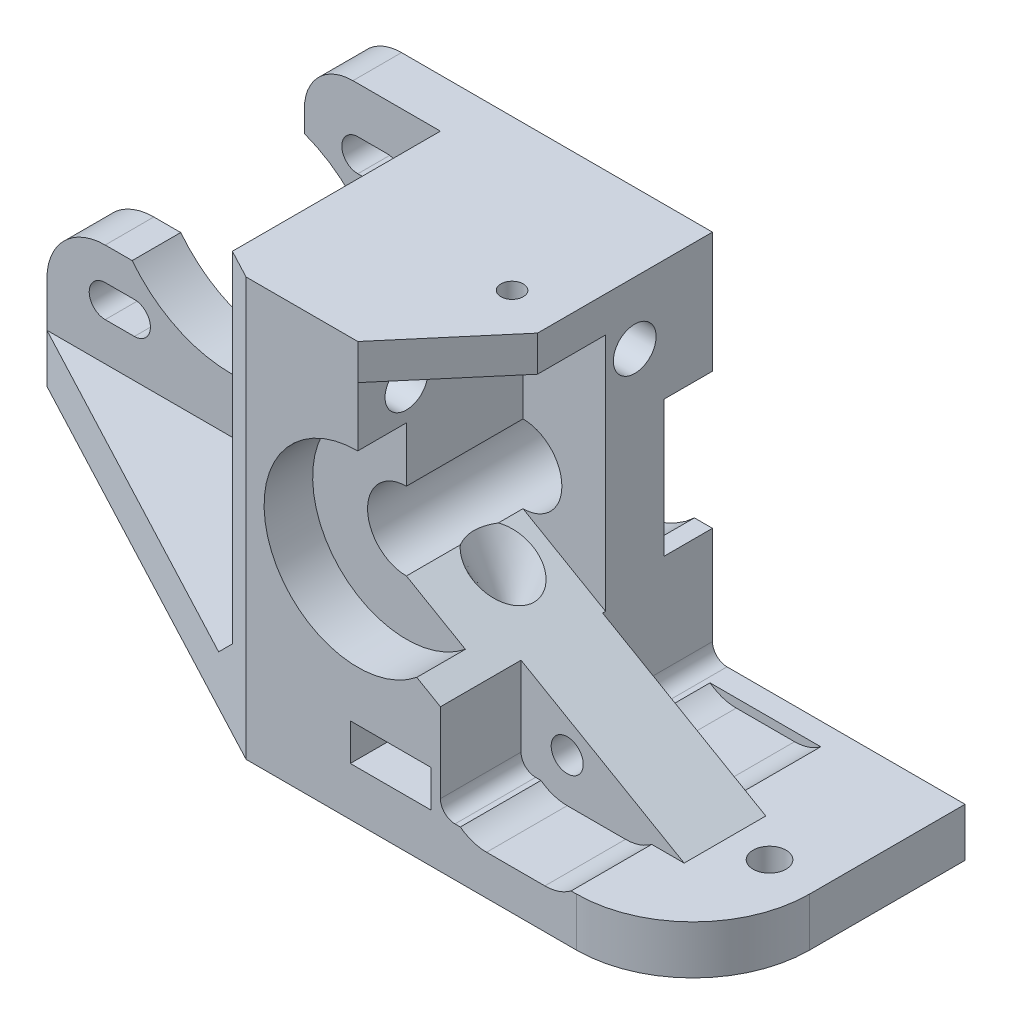
from build123d import *

# Parameters (mm, degrees)
SKETCH1_R                = 4
BOSS_EXTRUDE1_DEPTH      = 28
SKETCH2_W                = 40.5
SKETCH2_H                = 38
CUT_EXTRUDE1_DEPTH       = 23
SKETCH3_R                = 9.65
CUT_EXTRUDE2_DEPTH       = 5
SKETCH8_R                = 1.15
CUT_EXTRUDE7_DEPTH       = 44
CHAMFER1_SIZE            = 23
CHAMFER1_SIZE2           = 43.5
SKETCH9_R                = 2.2
CUT_EXTRUDE8_DEPTH       = 90.5
CUT_EXTRUDE9_DEPTH       = 3
CUT_EXTRUDE9_DEPTH_BACK  = 4
CHAMFER2_SIZE            = 3
SKETCH16_W               = 26
SKETCH16_H               = 38
CUT_EXTRUDE12_DEPTH      = 29.0000001
CUT_EXTRUDE3_DEPTH       = 5
FILLET6_R                = 1.5
CUT_EXTRUDE13_DEPTH      = 17
SKETCH21_R               = 1.65
BOSS_EXTRUDE3_DEPTH      = 4.2
BOSS_EXTRUDE3_DEPTH_BACK = 4.2
SKETCH15_R               = 1.7
CUT_EXTRUDE11_DEPTH      = 44
CUT_EXTRUDE14_DEPTH      = 9
CHAMFER4_SIZE            = 8.5
CHAMFER4_SIZE2           = 10
FILLET1_R                = 5
FILLET2_R                = 6
FILLET4_R                = 12
CUT_EXTRUDE15_DEPTH      = 3.8
CUT_EXTRUDE18_REACH      = 45
SKETCH26_R               = 3.15


with BuildPart() as part:
    # Sketch1 → Boss-Extrude1 (new body)
    with BuildSketch(Plane.XY):
        with BuildLine():
            Line((-55, -23.6), (34.5, -23.6))
            Line((34.5, -23.6), (34.5, 19.4))
            Line((34.5, 19.4), (-28.5, 19.4))
            Line((-28.5, 19.4), (-28.5, 12.180409823))
            ThreePointArc((-28.5, 12.180409823), (-20.217668105, -2.285689125), (-33, -12.985083113))
            Line((-33, -12.985083113), (-36, -12.985083113))
            ThreePointArc((-36, -12.985083113), (-41.689100041, -11.672468641), (-46.228019527, -8))
            Line((-46.228019527, -8), (-55, -8))
            Line((-55, -8), (-55, -23.6))
        make_face()
        Circle(SKETCH1_R, mode=Mode.SUBTRACT)
        with BuildLine():
            Line((-23, 11.35), (-20, 11.35))
            ThreePointArc((-20, 11.35), (-18.35, 13), (-20, 14.65))
            Line((-20, 14.65), (-23, 14.65))
            ThreePointArc((-23, 14.65), (-24.65, 13), (-23, 11.35))
        make_face(mode=Mode.SUBTRACT)
        with BuildLine():
            Line((-23, -14.65), (-20, -14.65))
            ThreePointArc((-20, -14.65), (-18.35, -13), (-20, -11.35))
            Line((-20, -11.35), (-23, -11.35))
            ThreePointArc((-23, -11.35), (-24.65, -13), (-23, -14.65))
        make_face(mode=Mode.SUBTRACT)
        with BuildLine():
            Line((-46, -11.35), (-49, -11.35))
            ThreePointArc((-49, -11.35), (-50.65, -13), (-49, -14.65))
            Line((-49, -14.65), (-46, -14.65))
            ThreePointArc((-46, -14.65), (-44.35, -13), (-46, -11.35))
        make_face(mode=Mode.SUBTRACT)
    extrude(amount=BOSS_EXTRUDE1_DEPTH)

    # Sketch2 → Cut-Extrude1 (cut)
    with BuildSketch(Plane.XY.offset(28)):
        with Locations((-34.75, 0.4)):
            Rectangle(SKETCH2_W, SKETCH2_H)
    extrude(amount=-CUT_EXTRUDE1_DEPTH, mode=Mode.SUBTRACT)

    # Sketch3 → Cut-Extrude2 (cut)
    with BuildSketch(Plane.XY.offset(28)):
        Circle(SKETCH3_R)
    extrude(amount=-CUT_EXTRUDE2_DEPTH, mode=Mode.SUBTRACT)

    # Sketch8 → Cut-Extrude7 (cut, through all)
    with BuildSketch(Plane.XZ.offset(23.6)):
        with Locations((3.375, 15.5)):
            Circle(SKETCH8_R)
    extrude(amount=-CUT_EXTRUDE7_DEPTH, mode=Mode.SUBTRACT)

    # Chamfer1
    chamfer1_edges = [part.edges().sort_by_distance(p)[0] for p in [
        (-55, -21.1, 28),
    ]]
    chamfer1_side = [part.faces().sort_by_distance(p)[0] for p in [
        (-55, -18.958031088, 10.841968912),
    ]]
    chamfer(chamfer1_edges, length=CHAMFER1_SIZE, length2=CHAMFER1_SIZE2, reference=chamfer1_side[0])

    # Sketch9 → Cut-Extrude8 (cut, through all)
    with BuildSketch(Plane(origin=(34.5, 0, 0), x_dir=(0, 0, -1), z_dir=(1, 0, 0))):
        with Locations((-8, 13)):
            Circle(SKETCH9_R)
        with Locations((-23, 13)):
            Circle(SKETCH9_R)
    extrude(amount=-CUT_EXTRUDE8_DEPTH, mode=Mode.SUBTRACT)

    # Sketch10 → Cut-Extrude9 (cut, two sides)
    with BuildSketch(Plane.ZY.offset(14.5)) as cut_extrude9_sk:
        Polygon((5.1, 14.674315781), (5.1, 11.325684219), (8, 9.651368439), (10.9, 11.325684219), (10.9, 14.674315781), (8, 16.348631561), align=None)
        Polygon((25.9, 11.325684219), (25.9, 14.674315781), (23, 16.348631561), (20.1, 14.674315781), (20.1, 11.325684219), (23, 9.651368439), align=None)
    extrude(amount=CUT_EXTRUDE9_DEPTH, mode=Mode.SUBTRACT)
    extrude(cut_extrude9_sk.sketch, amount=-CUT_EXTRUDE9_DEPTH_BACK, mode=Mode.SUBTRACT)

    # Chamfer2
    chamfer2_edges = [part.edges().sort_by_distance(p)[0] for p in [
        (-14.5, -18.6, 15.706896552),
    ]]
    chamfer(chamfer2_edges, length=CHAMFER2_SIZE)

    # Sketch16 → Cut-Extrude12 (cut, through all)
    with BuildSketch(Plane.XY.offset(28)):
        with Locations((21.5, 0.4)):
            Rectangle(SKETCH16_W, SKETCH16_H)
    extrude(amount=-CUT_EXTRUDE12_DEPTH, mode=Mode.SUBTRACT)

    # Sketch4 → Cut-Extrude3 (cut)
    with BuildSketch(Plane(origin=(0, 0, 0), x_dir=(-1, 0, 0), z_dir=(0, 0, -1))):
        with BuildLine():
            Line((-36.31147183, -7), (-6.642476948, -7))
            ThreePointArc((-6.642476948, -7), (9.65, 0), (-6.642476948, 7))
            Line((-6.642476948, 7), (-36.31147183, 7))
            Line((-36.31147183, 7), (-36.31147183, -7))
        make_face()
    extrude(amount=-CUT_EXTRUDE3_DEPTH, mode=Mode.SUBTRACT)

    # Fillet6
    fillet6_edges = [part.edges().sort_by_distance(p)[0] for p in [
        (8.5, -18.6, 14),
    ]]
    fillet(fillet6_edges, radius=FILLET6_R)

    # Sketch17 → Cut-Extrude13 (cut)
    with BuildSketch(Plane.XY.offset(28)):
        with BuildLine():
            Line((0, 4), (0, 15.733500455))
            Line((0, 15.733500455), (8.5, 15.733500455))
            Line((8.5, 15.733500455), (8.5, -8.907477288))
            Line((8.5, -8.907477288), (0, -4))
            ThreePointArc((0, -4), (4, 0), (0, 4))
        make_face()
    extrude(amount=-CUT_EXTRUDE13_DEPTH, mode=Mode.SUBTRACT)

    # Sketch20 → Cut-Revolve1 (revolve, cut)
    with BuildSketch(Plane.XY.offset(15.5)):
        Polygon((3.375, -11.8), (7.375, -3.8), (3.375, -3.8), align=None)
    revolve(axis=Axis((3.375, -3.8, 15.5), (0, -1, 0)), mode=Mode.SUBTRACT)

    # Sketch21 → Boss-Extrude3 (add, two sides)
    with BuildSketch(Plane.XY.offset(15.5)) as boss_extrude3_sk:
        Polygon((7.25, -8.185789452), (7.25, -18.6), (25.287941791, -18.6), align=None)
        with Locations((13.25, -15)):
            Circle(SKETCH21_R, mode=Mode.SUBTRACT)
    extrude(amount=BOSS_EXTRUDE3_DEPTH)
    extrude(boss_extrude3_sk.sketch, amount=-BOSS_EXTRUDE3_DEPTH_BACK)

    # Sketch15 → Cut-Extrude11 (cut, through all)
    with BuildSketch(Plane.XZ.offset(23.6)):
        with Locations((-20.625, 15)):
            Circle(SKETCH15_R)
        with Locations((29.375, 15)):
            Circle(SKETCH15_R)
    extrude(amount=-CUT_EXTRUDE11_DEPTH, mode=Mode.SUBTRACT)

    # Sketch22 → Cut-Extrude14 (cut)
    with BuildSketch(Plane.XY.offset(19.7)):
        with BuildLine():
            Line((13.25, -19.5), (19.25, -19.5))
            ThreePointArc((19.25, -19.5), (23.75, -15), (19.25, -10.5))
            Line((19.25, -10.5), (13.25, -10.5))
            ThreePointArc((13.25, -10.5), (8.75, -15), (13.25, -19.5))
        make_face()
    cut_extrude14 = extrude(amount=CUT_EXTRUDE14_DEPTH, mode=Mode.SUBTRACT)

    # Mirror1: Cut-Extrude14 across plane
    add(cut_extrude14.mirror(Plane.XY.offset(15.5)), mode=Mode.SUBTRACT)

    # Chamfer4
    chamfer4_edges = [part.edges().sort_by_distance(p)[0] for p in [
        (8.5, 17.566750228, 28),
    ]]
    chamfer4_side = [part.faces().sort_by_distance(p)[0] for p in [
        (7.87031754, -13.003738644, 28),
    ]]
    chamfer(chamfer4_edges, length=CHAMFER4_SIZE, length2=CHAMFER4_SIZE2, reference=chamfer4_side[0])

    # Fillet1
    fillet1_edges = [part.edges().sort_by_distance(p)[0] for p in [
        (-28.5, 19.4, 2.5),
    ]]
    fillet(fillet1_edges, radius=FILLET1_R)

    # Fillet2
    fillet2_edges = [part.edges().sort_by_distance(p)[0] for p in [
        (-55, -8, 2.5),
    ]]
    fillet(fillet2_edges, radius=FILLET2_R)

    # Fillet4
    fillet4_edges = [part.edges().sort_by_distance(p)[0] for p in [
        (34.5, -21.1, 28),
    ]]
    fillet(fillet4_edges, radius=FILLET4_R)

    # Sketch23 → Cut-Extrude15 (cut)
    with BuildSketch(Plane.XZ.offset(18.6)):
        Polygon((-0.775, 28.722034997), (7.525, 28.722034997), (7.525, 13.103996383), (3.375, 10.707992766), (-0.775, 13.103996383), align=None)
    extrude(amount=-CUT_EXTRUDE15_DEPTH, mode=Mode.SUBTRACT)

    # Sketch26 → Cut-Extrude18 (cut, up to next)
    with BuildSketch(Plane.XZ.offset(23.6), mode=Mode.PRIVATE) as cut_extrude18_sk1:
        with Locations((3.375, 15.5)):
            Circle(SKETCH26_R)
    cut_extrude18_tool1 = extrude(cut_extrude18_sk1.sketch, amount=-CUT_EXTRUDE18_REACH, mode=Mode.PRIVATE) & part.part
    add(cut_extrude18_tool1.solids().sort_by_distance((3.375, -23.6, 15.5))[0], mode=Mode.SUBTRACT)


solid = part.part
